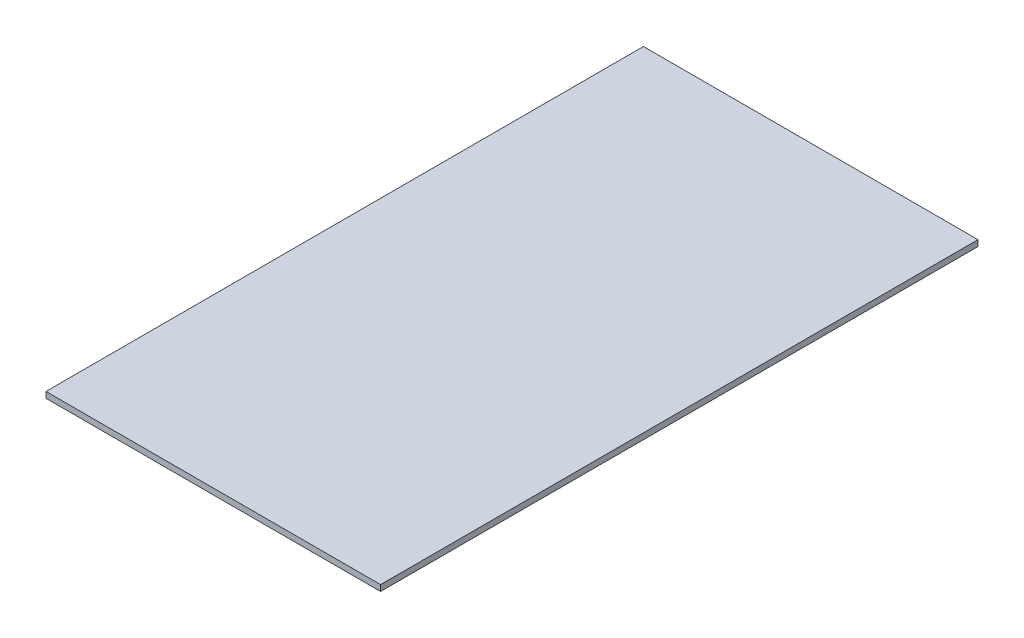
from build123d import *

# Parameters (mm, degrees)
SKETCH1_W           = 355.6
SKETCH1_H           = 635
BOSS_EXTRUDE1_DEPTH = 6.35


with BuildPart() as part:
    # Sketch1 → Boss-Extrude1 (new body)
    with BuildSketch(Plane(origin=(0, 0, 0), x_dir=(1, 0, 0), z_dir=(0, 1, 0))):
        with Locations((177.8, 317.5)):
            Rectangle(SKETCH1_W, SKETCH1_H)
    extrude(amount=BOSS_EXTRUDE1_DEPTH)


solid = part.part
